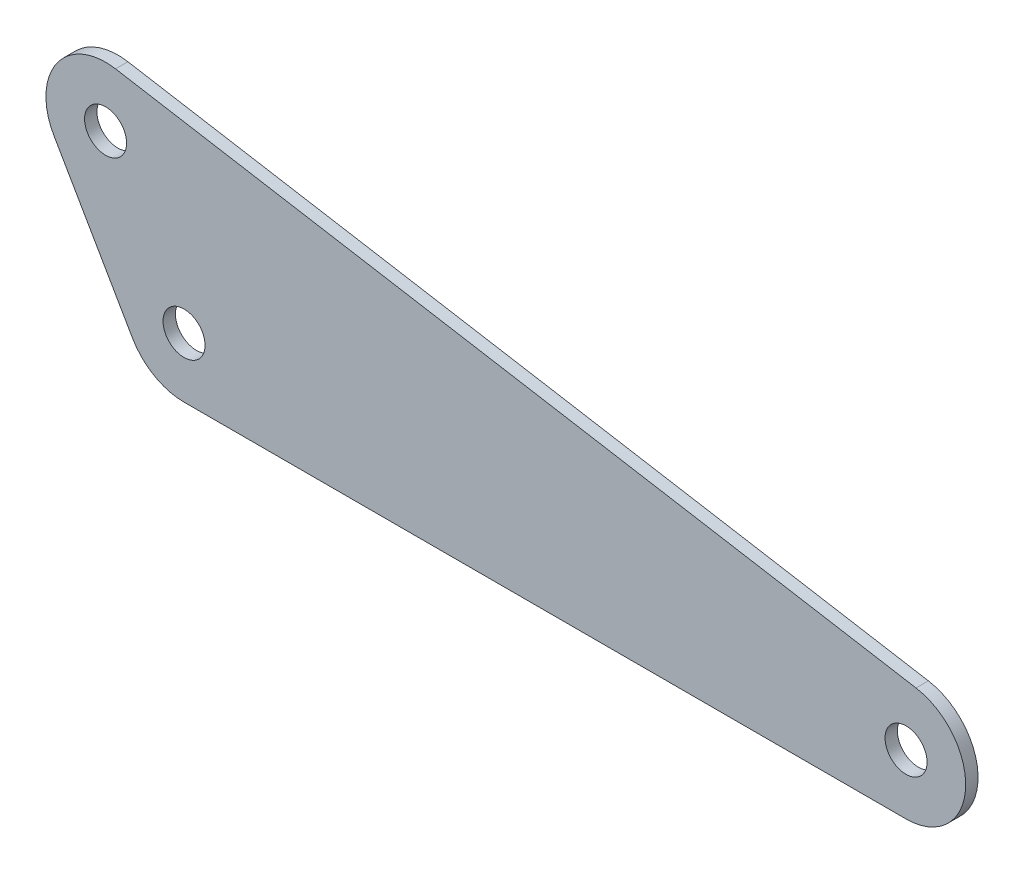
from build123d import *

# Parameters (mm, degrees)
SKETCH1_R           = 8.5
BOSS_EXTRUDE1_DEPTH = 5
CUT_EXTRUDE1_DEPTH  = 6


with BuildPart() as part:
    # Sketch1 → Boss-Extrude1 (new body)
    with BuildSketch(Plane.XY):
        with BuildLine():
            Line((0, -31.75), (292.1, -31.75))
            ThreePointArc((292.1, -31.75), (323.737779408, -2.667098451), (297.415343146, 31.30191092))
            Line((297.415343146, 31.30191092), (-26.434656854, 86.29452406))
            ThreePointArc((-26.434656854, 86.29452406), (-57.815571461, 73.121277857), (-59.24630657, 39.11761314))
            Line((-59.24630657, 39.11761314), (-27.49630657, -15.875))
            ThreePointArc((-27.49630657, -15.875), (-15.875, -27.49630657), (0, -31.75))
        make_face()
        with Locations((-31.75, 54.99261314)):
            Circle(SKETCH1_R, mode=Mode.SUBTRACT)
        Circle(SKETCH1_R, mode=Mode.SUBTRACT)
        with Locations((292.1, 0)):
            Circle(SKETCH1_R, mode=Mode.SUBTRACT)
    extrude(amount=BOSS_EXTRUDE1_DEPTH)

    # Sketch2 → Cut-Extrude1 (cut, through all)
    with BuildSketch(Plane.XY.offset(5)):
        with BuildLine():
            Line((297.415343146, 31.30191092), (-26.434656854, 86.29452406))
            ThreePointArc((-26.434656854, 86.29452406), (-57.815571461, 73.121277857), (-59.24630657, 39.11761314))
            Line((-59.24630657, 39.11761314), (-27.49630657, -15.875))
            ThreePointArc((-27.49630657, -15.875), (-15.875, -27.49630657), (0, -31.75))
            Line((0, -31.75), (292.1, -31.75))
            ThreePointArc((292.1, -31.75), (323.737779408, -2.667098451), (297.415343146, 31.30191092))
        make_face()
        with BuildLine():
            Line((296.139660791, 23.789452299), (-27.710339209, 78.782065439))
            ThreePointArc((-27.710339209, 78.782065439), (-51.55983431, 68.770398325), (-52.647192993, 42.92761314))
            Line((-52.647192993, 42.92761314), (-20.897192993, -12.065))
            ThreePointArc((-20.897192993, -12.065), (-12.065, -20.897192993), (0, -24.13))
            Line((0, -24.13), (292.1, -24.13))
            ThreePointArc((292.1, -24.13), (316.14471235, -2.026994822), (296.139660791, 23.789452299))
        make_face(mode=Mode.SUBTRACT)
    extrude(amount=-CUT_EXTRUDE1_DEPTH, mode=Mode.SUBTRACT)


solid = part.part
